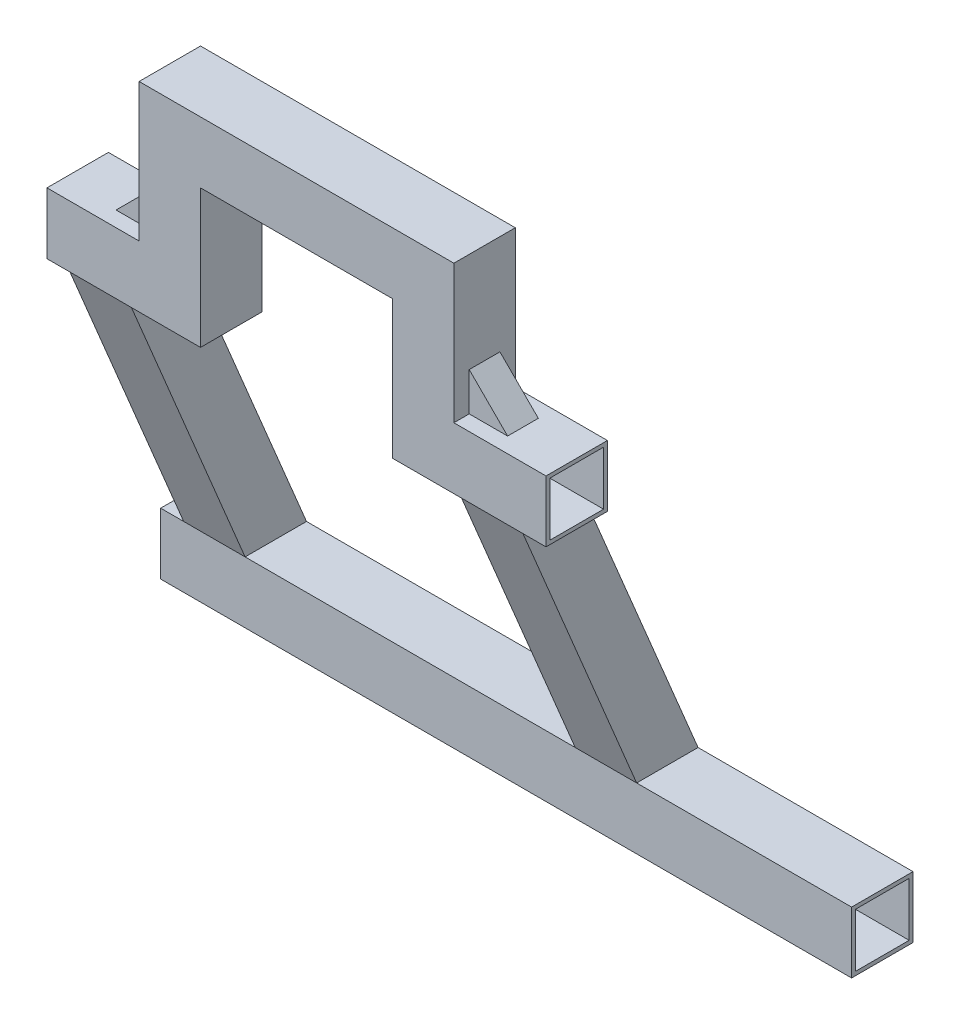
from build123d import *

# Parameters (mm, degrees)
EXTRUDE_1_DEPTH     = 80
SKETCH_2_W          = 80
SKETCH_2_H          = 80
SKETCH_2_W_2        = 70
SKETCH_2_H_2        = 70
EXTRUDE_2_DEPTH     = 385
SKETCH_4_W          = 900
SKETCH_4_H          = 80
EXTRUDE_3_DEPTH     = 80
EXTRUDE_5_DEPTH     = 40
SKETCH_8_W          = 70
SKETCH_8_H          = 70
CUT_EXTRUDE_1_DEPTH = 1011.686172094


with BuildPart() as part:
    # 草图1 → 凸台-拉伸1 (new body)
    with BuildSketch(Plane.XY):
        Polygon((-125, 180), (125, 180), (125, 0), (325, 0), (325, 80), (205, 80), (205, 260), (-205, 260), (-205, 80), (-325, 80), (-325, 0), (-125, 0), align=None)
    extrude(amount=EXTRUDE_1_DEPTH)

    # 草图2 → 凸台-拉伸2 (add, along a direction that is not the sketch's normal)
    # profile 1 of 2: a face of its own
    with BuildSketch(Plane.XZ):
        with Locations((-255, 40)):
            Rectangle(SKETCH_2_W, SKETCH_2_H)
        with Locations((-255, 40)):
            Rectangle(SKETCH_2_W_2, SKETCH_2_H_2, mode=Mode.SUBTRACT)
    # profile 2 of 2: a face of its own
    with BuildSketch(Plane.XZ):
        with Locations((255, 40)):
            Rectangle(SKETCH_2_W, SKETCH_2_H)
        with Locations((255, 40)):
            Rectangle(SKETCH_2_W_2, SKETCH_2_H_2, mode=Mode.SUBTRACT)
    extrude(amount=EXTRUDE_2_DEPTH, dir=(0, -0.923076923076923, -0.3846153846153847))

    # 草图4 → 凸台-拉伸3 (add)
    with BuildSketch(Plane.XZ.offset(355.384615385)):
        with Locations((125, -108.076923077)):
            Rectangle(SKETCH_4_W, SKETCH_4_H)
    extrude(amount=EXTRUDE_3_DEPTH)

    # 草图6 → 凸台-拉伸5 (add)
    with BuildSketch(Plane.XY.offset(20)):
        Polygon((-205, 130), (-255, 80), (-205, 80), align=None)
        Polygon((205, 130), (255, 80), (205, 80), align=None)
    extrude(amount=EXTRUDE_5_DEPTH)

    # 草图8 → 切除-拉伸1 (cut, through all)
    with BuildSketch(Plane.ZY.offset(325)):
        with Locations((-108.076923077, -395.384615385)):
            Rectangle(SKETCH_8_W, SKETCH_8_H)
    extrude(amount=-CUT_EXTRUDE_1_DEPTH, mode=Mode.SUBTRACT)

    # 切除-扫描1: sweep along a path in 草图10
    with BuildLine(Plane(origin=(0, 0, 40), x_dir=(-1, 0, 0), z_dir=(0, 0, -1))) as sweep_1_path:
        Line((-325, 40), (-165, 40))
        Line((-165, 40), (-165, 220))
        Line((-165, 220), (165, 220))
        Line((165, 220), (165, 40))
        Line((165, 40), (325, 40))
    # 草图9 → 切除-扫描1 (sweep, cut)
    with BuildSketch(Plane(origin=(325, 0, 0), x_dir=(0, 0, -1), z_dir=(1, 0, 0))):
        Polygon((-5, 5), (-5, 75), (-20, 75), (-60, 75), (-75, 75), (-75, 5), align=None)
    sweep(path=sweep_1_path.line, transition=Transition.RIGHT, mode=Mode.SUBTRACT)


solid = part.part
